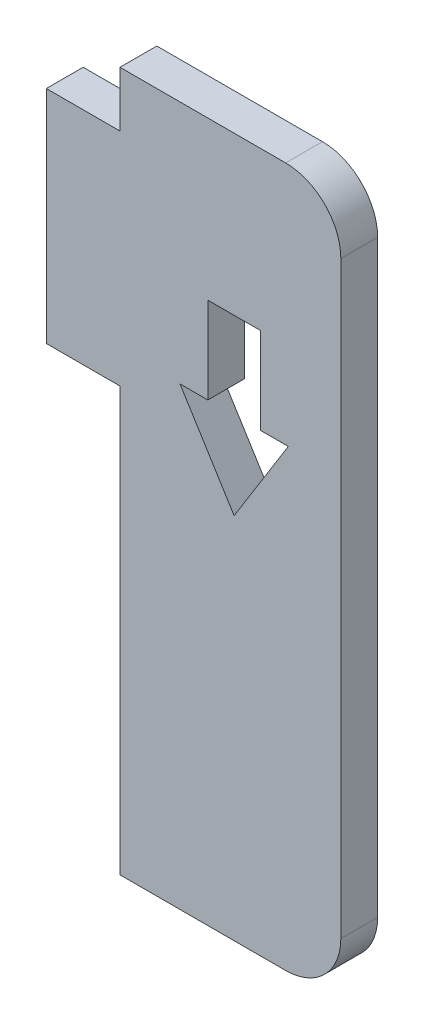
from build123d import *

# Parameters (mm, degrees)
SKETCH_1_W          = 12
SKETCH_1_H          = 10
EXTRUDE_1_DEPTH     = 2
CUT_EXTRUDE_1_DEPTH = 2
FILLET_1_R          = 3


with BuildPart() as part:
    # ｽｹｯﾁ1 → ﾎﾞｽ - 押し出し1 (new body)
    with BuildSketch(Plane.XY):
        Polygon((4, 0), (0, 0), (0, -12), (4, -12), (4, -25), (16, -25), (16, 3), (4, 3), align=None)
        with Locations((10, -30)):
            Rectangle(SKETCH_1_W, SKETCH_1_H)
    extrude(amount=EXTRUDE_1_DEPTH)

    # ｽｹｯﾁ2 → ｶｯﾄ - 押し出し1 (cut)
    with BuildSketch(Plane.XY.offset(2)):
        Polygon((11.632823949, -5.570087609), (8.772941266, -5.570087609), (8.772941266, -10.268637818), (7.260776917, -10.268637818), (10.202882607, -14.99997105), (13.144988298, -10.268637818), (11.632823949, -10.268637818), align=None)
    extrude(amount=-CUT_EXTRUDE_1_DEPTH, mode=Mode.SUBTRACT)

    # ﾌｨﾚｯﾄ1
    fillet_1_edges = [part.edges().sort_by_distance(p)[0] for p in [
        (16, 3, 1),
        (16, -35, 1),
    ]]
    fillet(fillet_1_edges, radius=FILLET_1_R)


solid = part.part
